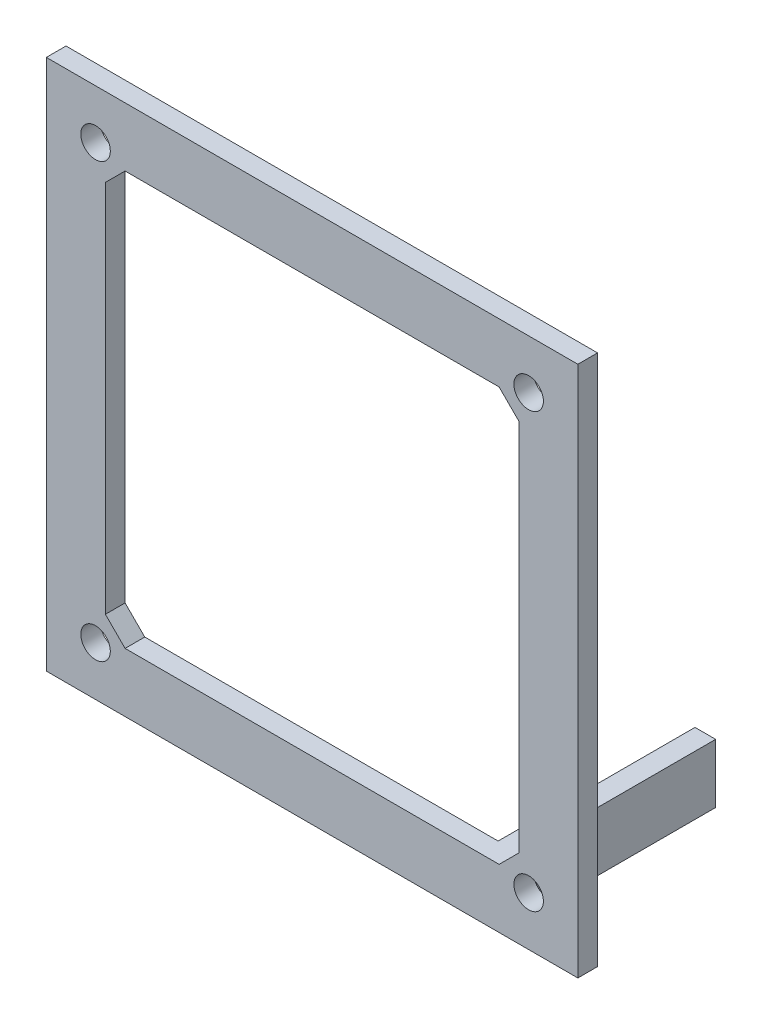
from build123d import *

# Parameters (mm, degrees)
CROQUIS1_W              = 50
CROQUIS1_H              = 50
CROQUIS1_R              = 1.5
SALIENTE_EXTRUIR1_DEPTH = 2
CROQUIS2_W              = 54
CROQUIS2_H              = 54
CROQUIS2_W_2            = 50
CROQUIS2_H_2            = 50
SALIENTE_EXTRUIR2_DEPTH = 2
CROQUIS3_W              = 2.1
CROQUIS3_H              = 6
SALIENTE_EXTRUIR3_DEPTH = 20


with BuildPart() as part:
    # Croquis1 → Saliente-Extruir1 (new body)
    with BuildSketch(Plane.XY):
        with Locations((-48.774779829, -1.232610977)):
            Rectangle(CROQUIS1_W, CROQUIS1_H)
        with Locations((-70.774779829, 20.767389023)):
            Circle(CROQUIS1_R, mode=Mode.SUBTRACT)
        with Locations((-26.774779829, 20.767389023)):
            Circle(CROQUIS1_R, mode=Mode.SUBTRACT)
        with Locations((-26.774779829, -23.232610977)):
            Circle(CROQUIS1_R, mode=Mode.SUBTRACT)
        with Locations((-70.774779829, -23.232610977)):
            Circle(CROQUIS1_R, mode=Mode.SUBTRACT)
        Polygon((-69.774779829, 17.767389023), (-67.774779829, 19.767389023), (-29.774779829, 19.767389023), (-27.774779829, 17.767389023), (-27.774779829, -20.232610977), (-29.774779829, -22.232610977), (-67.774779829, -22.232610977), (-69.774779829, -20.232610977), align=None, mode=Mode.SUBTRACT)
    extrude(amount=SALIENTE_EXTRUIR1_DEPTH)

    # Croquis2 → Saliente-Extruir2 (add)
    with BuildSketch(Plane(origin=(0, 0, 0), x_dir=(-1, 0, 0), z_dir=(0, 0, -1))):
        with Locations((48.774779829, -1.232610977)):
            Rectangle(CROQUIS2_W, CROQUIS2_H)
        with Locations((48.774779829, -1.232610977)):
            Rectangle(CROQUIS2_W_2, CROQUIS2_H_2, mode=Mode.SUBTRACT)
    extrude(amount=-SALIENTE_EXTRUIR2_DEPTH)

    # Croquis3 → Saliente-Extruir3 (add)
    with BuildSketch(Plane(origin=(0, 0, 0), x_dir=(-1, 0, 0), z_dir=(0, 0, -1))):
        with Locations((30.824779829, -25.232610977)):
            Rectangle(CROQUIS3_W, CROQUIS3_H)
    extrude(amount=SALIENTE_EXTRUIR3_DEPTH)


solid = part.part
